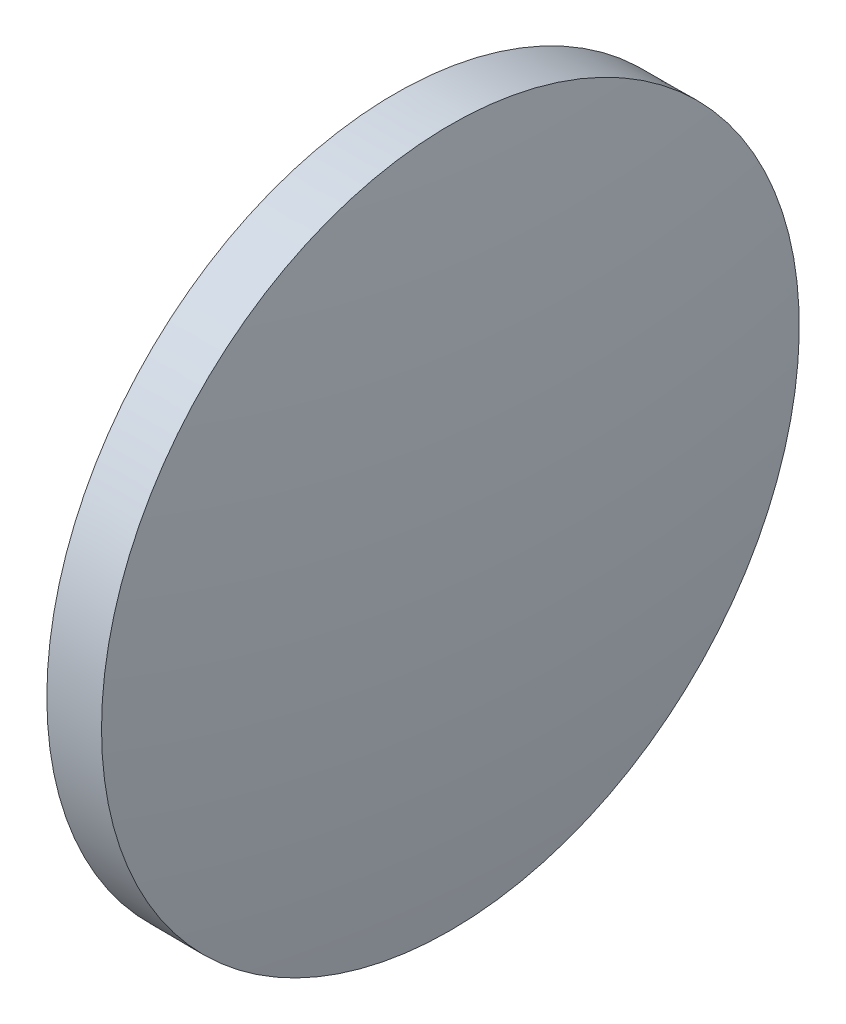
from build123d import *


with BuildPart() as part:
    # 草图1 one side → 旋转1 (revolve)
    with BuildSketch(Plane.XY, mode=Mode.PRIVATE) as revolve_1_sk:
        Polygon((87.486610804, 48.632092139), (87.486610804, 61.336266368), (85.486628228, 61.32791791), (85.486619519, 48.632092139), align=None)
        with BuildLine():
            Line((84.536612527, 48.632092139), (85.486619519, 48.632092139))
            Line((85.486619519, 48.632092139), (85.486628228, 61.32791791))
            ThreePointArc((85.486628228, 61.32791791), (84.77460557, 54.997740601), (84.536612527, 48.632092139))
        make_face()
        with BuildLine():
            Line((87.486610804, 48.632092139), (88.437246013, 48.632092139))
            ThreePointArc((88.437246013, 48.632092139), (88.199255457, 55.001938098), (87.486610804, 61.336266368))
            Line((87.486610804, 61.336266368), (87.486610804, 48.632092139))
        make_face()
    revolve(revolve_1_sk.sketch.rotate(Axis((79.331467404, 48.632092139, 0), (1, 0, 0)), 180), axis=Axis((79.331467404, 48.632092139, 0), (1, 0, 0)))  # turned: the seam where the file's is


solid = part.part
